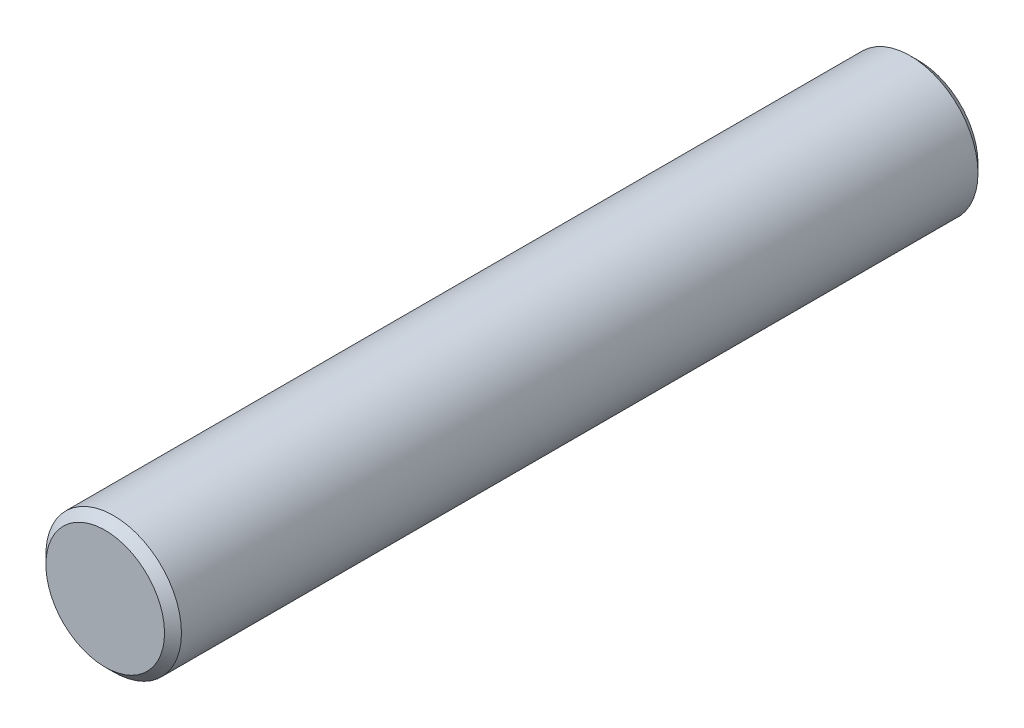
from build123d import *

# Parameters (mm, degrees)
SKETCH2_R           = 8
BOSS_EXTRUDE1_DEPTH = 48
CHAMFER1_SIZE       = 1


with BuildPart() as part:
    # Sketch2 → Boss-Extrude1 (new body, symmetric)
    with BuildSketch(Plane.XY):
        Circle(SKETCH2_R)
    extrude(amount=BOSS_EXTRUDE1_DEPTH, both=True)

    # Chamfer1
    chamfer1_edges = [part.edges().sort_by_distance(p)[0] for p in [
        (-8, 0, -48),
        (-8, 0, 48),
    ]]
    chamfer(chamfer1_edges, length=CHAMFER1_SIZE)


solid = part.part
